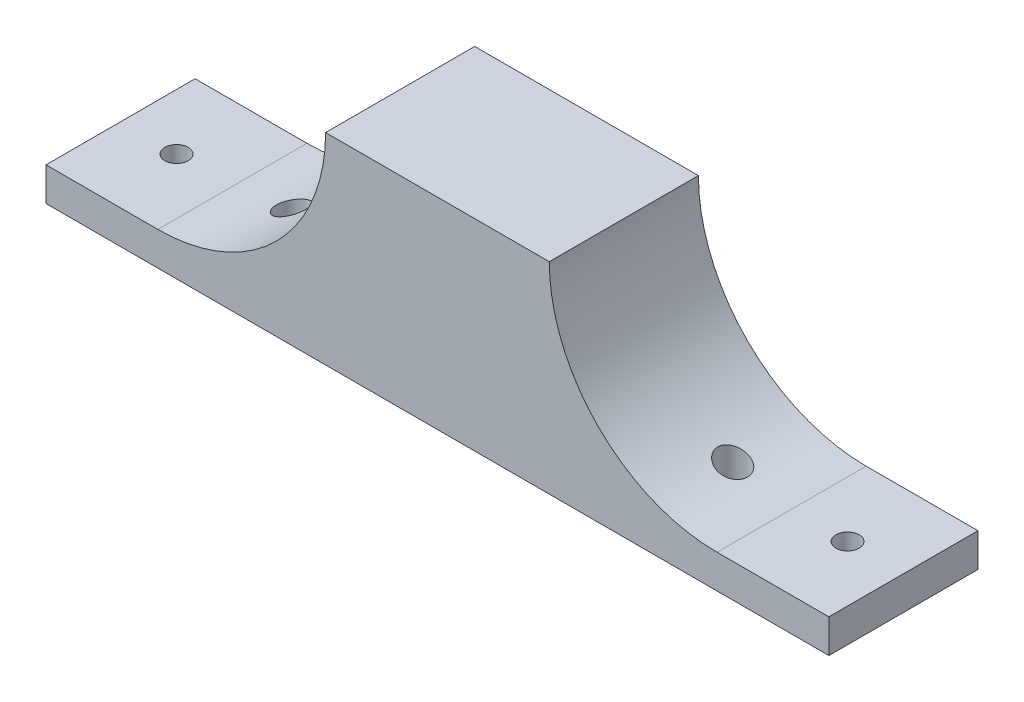
from build123d import *

# Parameters (mm, degrees)
SKETCH1_W                    = 60
SKETCH1_H                    = 40
BOSS_EXTRUDE1_DEPTH          = 54
SKETCH3_W                    = 75
SKETCH3_H                    = 40
SKETCH3_R                    = 4
BOSS_EXTRUDE2_DEPTH          = 54
CUT_EXTRUDE2_DEPTH           = 60
TAP_DRILL_FOR_M6_HELICOIL1_D = 6.25


with BuildPart() as part:
    # Sketch1 → Boss-Extrude1 (new body)
    with BuildSketch(Plane(origin=(0, 0, 0), x_dir=(1, 0, 0), z_dir=(0, 1, 0))):
        with Locations((-30, -20)):
            Rectangle(SKETCH1_W, SKETCH1_H)
    extrude(amount=BOSS_EXTRUDE1_DEPTH)

    # Sketch3 → Boss-Extrude2 (add)
    with BuildSketch(Plane(origin=(0, 0, 0), x_dir=(1, 0, 0), z_dir=(0, 1, 0))):
        with Locations((37.5, -20)):
            Rectangle(SKETCH3_W, SKETCH3_H)
        with Locations((29.2, -20)):
            Circle(SKETCH3_R, mode=Mode.SUBTRACT)
    boss_extrude2 = extrude(amount=BOSS_EXTRUDE2_DEPTH)

    # Sketch4 → Cut-Extrude2 (cut)
    with BuildSketch(Plane.XY.offset(40)):
        with BuildLine():
            ThreePointArc((75, 20.458980338), (61.05699404, 11.962243847), (45, 9))
            Line((45, 9), (75, 9))
            Line((75, 9), (75, 20.458980338))
        make_face()
        with BuildLine():
            Line((45, 9), (45, 54))
            Line((45, 54), (0, 54))
            ThreePointArc((0, 54), (13.180194847, 22.180194847), (45, 9))
        make_face()
        with BuildLine():
            Line((75, 54), (45, 54))
            Line((45, 54), (45, 9))
            ThreePointArc((45, 9), (61.05699404, 11.962243847), (75, 20.458980338))
            Line((75, 20.458980338), (75, 54))
        make_face()
    cut_extrude2 = extrude(amount=-CUT_EXTRUDE2_DEPTH, mode=Mode.SUBTRACT)

    # Tap Drill for M6 Helicoil1 (through all)
    with Locations(Plane(origin=(0, 9, 0), x_dir=(1, 0, 0), z_dir=(0, 1, 0))):
        with Locations((60, -20)):
            tap_drill_for_m6_helicoil1 = Hole(TAP_DRILL_FOR_M6_HELICOIL1_D / 2)

    # Mirror1: Boss-Extrude2, Cut-Extrude2, Tap Drill for M6 Helicoil1 across plane
    add(boss_extrude2.mirror(Plane(origin=(-30, 0, 0), x_dir=(0, 0, 1), z_dir=(1, 0, 0))))
    add(cut_extrude2.mirror(Plane(origin=(-30, 0, 0), x_dir=(0, 0, 1), z_dir=(1, 0, 0))), mode=Mode.SUBTRACT)
    add(tap_drill_for_m6_helicoil1.mirror(Plane(origin=(-30, 0, 0), x_dir=(0, 0, 1), z_dir=(1, 0, 0))), mode=Mode.SUBTRACT)


solid = part.part
